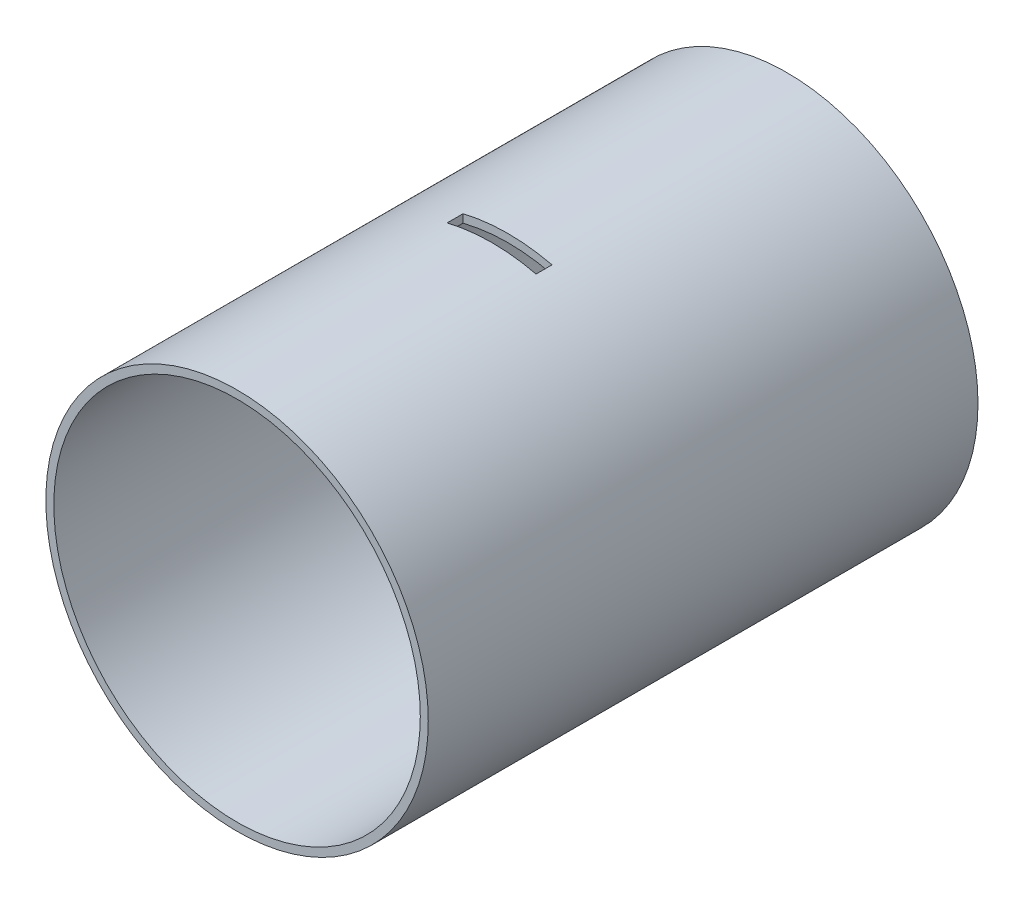
from build123d import *

# Parameters (mm, degrees)
SKETCH1_R           = 152.4
SKETCH1_R_2         = 146.05
BOSS_EXTRUDE1_DEPTH = 438.15
SKETCH2_W           = 70.919063033
SKETCH2_H           = 12.7
CUT_EXTRUDE1_DEPTH  = 400.05
SKETCH3_W           = 12.7
SKETCH3_H           = 25.42329985
CUT_EXTRUDE2_DEPTH  = 508


with BuildPart() as part:
    # Sketch1 → Boss-Extrude1 (new body)
    with BuildSketch(Plane.XY):
        Circle(SKETCH1_R)
        Circle(SKETCH1_R_2, mode=Mode.SUBTRACT)
    extrude(amount=BOSS_EXTRUDE1_DEPTH)

    # Sketch2 → Cut-Extrude1 (cut, symmetric)
    with BuildSketch(Plane(origin=(0, 0, 0), x_dir=(1, 0, 0), z_dir=(0, 1, 0))):
        with Locations((-0.319607005, -228.6)):
            Rectangle(SKETCH2_W, SKETCH2_H)
    extrude(amount=CUT_EXTRUDE1_DEPTH, both=True, mode=Mode.SUBTRACT)

    # Sketch3 → Cut-Extrude2 (cut)
    with BuildSketch(Plane(origin=(0, 0, 0), x_dir=(0, 0, -1), z_dir=(1, 0, 0))):
        with Locations((-228.6, 0)):
            Rectangle(SKETCH3_W, SKETCH3_H)
    extrude(amount=-CUT_EXTRUDE2_DEPTH, mode=Mode.SUBTRACT)


solid = part.part
